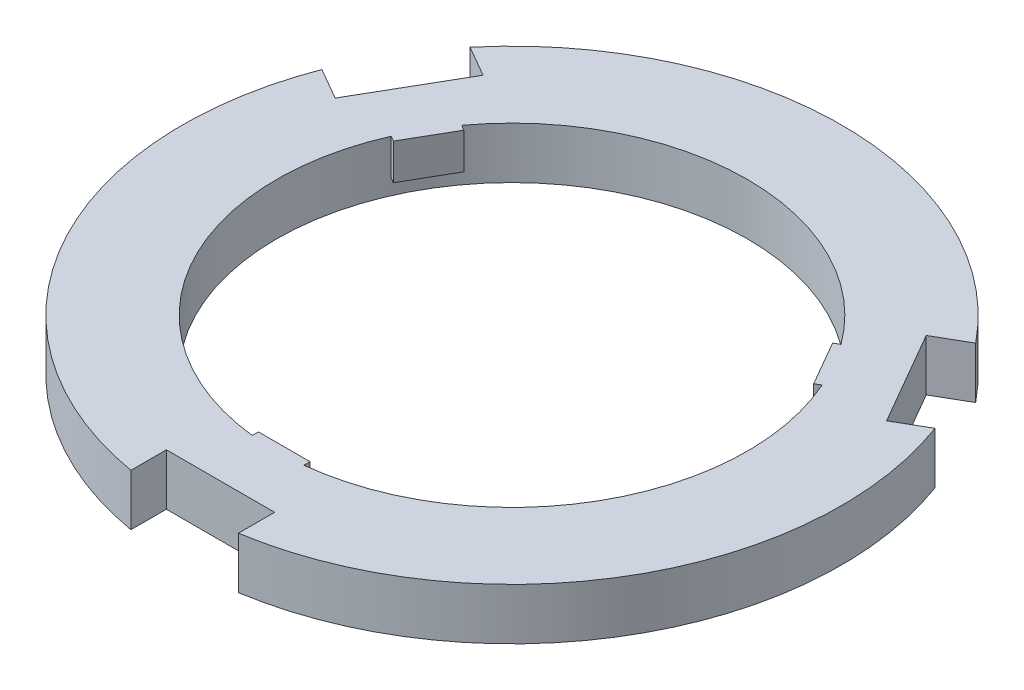
from build123d import *

# Parameters (mm, degrees)
BOSS_EXTRUDE4_DEPTH      = 3
BOSS_EXTRUDE5_START      = -2
BOSS_EXTRUDE5_DEPTH      = 2
BOSS_EXTRUDE6_DEPTH      = 3
BOSS_EXTRUDE6_DEPTH_BACK = 0.5


with BuildPart() as part:
    # Sketch2 → Boss-Extrude4 (new body)
    with BuildSketch(Plane(origin=(0, 0, 0), x_dir=(1, 0, 0), z_dir=(0, 1, 0))):
        with BuildLine():
            Line((-5.466491508, -31.529628456), (-5.466491508, -28.085827415))
            Line((-5.466491508, -28.085827415), (5.040547776, -28.085827415))
            Line((5.040547776, -28.085827415), (5.040547776, -31.600520219))
            ThreePointArc((5.040547776, -31.600520219), (27.604231444, -16.186611949), (30.038704969, 11.030693713))
            Line((30.038704969, 11.030693713), (27.056285781, 9.308793192))
            Line((27.056285781, 9.308793192), (21.802766139, 18.408156131))
            Line((21.802766139, 18.408156131), (24.846579394, 20.165502533))
            ThreePointArc((24.846579394, 20.165502533), (0.215901427, 31.999271657), (-24.572213461, 20.498934743))
            Line((-24.572213461, 20.498934743), (-21.589794274, 18.777034223))
            Line((-21.589794274, 18.777034223), (-26.843313916, 9.677671284))
            Line((-26.843313916, 9.677671284), (-29.887127171, 11.435017686))
            ThreePointArc((-29.887127171, 11.435017686), (-27.820132871, -15.812659708), (-5.466491508, -31.529628456))
        make_face()
        with BuildLine():
            ThreePointArc((2.502594182, -22.712052772), (0, -22.849514629), (-2.502594182, -22.712052772))
            ThreePointArc((-2.502594182, -22.712052772), (-19.788260133, -11.424757314), (-20.920511764, 9.188716249))
            ThreePointArc((-20.920511764, 9.188716249), (-19.788260133, 11.424757314), (-18.417917582, 13.523336524))
            ThreePointArc((-18.417917582, 13.523336524), (0, 22.849514629), (18.417917582, 13.523336524))
            ThreePointArc((18.417917582, 13.523336524), (19.788260133, 11.424757314), (20.920511764, 9.188716249))
            ThreePointArc((20.920511764, 9.188716249), (22.362064511, 4.69450632), (22.849514629, 0))
            ThreePointArc((22.849514629, 0), (17.018862787, -15.246593987), (2.502594182, -22.712052772))
        make_face(mode=Mode.SUBTRACT)
    extrude(amount=BOSS_EXTRUDE4_DEPTH)

    # Sketch2_12 → Boss-Extrude5 (add)
    with BuildSketch(Plane(origin=(0, 0, 0), x_dir=(1, 0, 0), z_dir=(0, 1, 0)).offset(BOSS_EXTRUDE5_START)):
        with BuildLine():
            Line((-5.466491508, -31.529628456), (-5.466491508, -28.085827415))
            Line((-5.466491508, -28.085827415), (5.040547776, -28.085827415))
            Line((5.040547776, -28.085827415), (5.040547776, -31.600520219))
            ThreePointArc((5.040547776, -31.600520219), (27.604231444, -16.186611949), (30.038704969, 11.030693713))
            Line((30.038704969, 11.030693713), (27.056285781, 9.308793192))
            Line((27.056285781, 9.308793192), (21.802766139, 18.408156131))
            Line((21.802766139, 18.408156131), (24.846579394, 20.165502533))
            ThreePointArc((24.846579394, 20.165502533), (0.215901427, 31.999271657), (-24.572213461, 20.498934743))
            Line((-24.572213461, 20.498934743), (-21.589794274, 18.777034223))
            Line((-21.589794274, 18.777034223), (-26.843313916, 9.677671284))
            Line((-26.843313916, 9.677671284), (-29.887127171, 11.435017686))
            ThreePointArc((-29.887127171, 11.435017686), (-27.820132871, -15.812659708), (-5.466491508, -31.529628456))
        make_face()
        with BuildLine():
            ThreePointArc((2.502594182, -22.712052772), (0, -22.849514629), (-2.502594182, -22.712052772))
            ThreePointArc((-2.502594182, -22.712052772), (-19.788260133, -11.424757314), (-20.920511764, 9.188716249))
            ThreePointArc((-20.920511764, 9.188716249), (-19.788260133, 11.424757314), (-18.417917582, 13.523336524))
            ThreePointArc((-18.417917582, 13.523336524), (0, 22.849514629), (18.417917582, 13.523336524))
            ThreePointArc((18.417917582, 13.523336524), (19.788260133, 11.424757314), (20.920511764, 9.188716249))
            ThreePointArc((20.920511764, 9.188716249), (22.362064511, 4.69450632), (22.849514629, 0))
            ThreePointArc((22.849514629, 0), (17.018862787, -15.246593987), (2.502594182, -22.712052772))
        make_face(mode=Mode.SUBTRACT)
    extrude(amount=BOSS_EXTRUDE5_DEPTH)

    # Sketch2_13 → Boss-Extrude6 (add, two sides: drawn at the far end of the back side and taken through both)
    with BuildSketch(Plane(origin=(0, 0, 0), x_dir=(1, 0, 0), z_dir=(0, 1, 0)).offset(-BOSS_EXTRUDE6_DEPTH_BACK)):
        with BuildLine():
            Line((2.502594182, -22.112052772), (-2.502594182, -22.112052772))
            Line((-2.502594182, -22.112052772), (-2.502594182, -22.712052772))
            ThreePointArc((-2.502594182, -22.712052772), (0, -22.849514629), (2.502594182, -22.712052772))
            Line((2.502594182, -22.712052772), (2.502594182, -22.112052772))
        make_face()
        with BuildLine():
            ThreePointArc((-18.417917582, 13.523336524), (-19.788260133, 11.424757314), (-20.920511764, 9.188716249))
            Line((-20.920511764, 9.188716249), (-20.400896522, 8.888716249))
            Line((-20.400896522, 8.888716249), (-17.89830234, 13.223336524))
            Line((-17.89830234, 13.223336524), (-18.417917582, 13.523336524))
        make_face()
        with BuildLine():
            Line((20.400896522, 8.888716249), (20.920511764, 9.188716249))
            ThreePointArc((20.920511764, 9.188716249), (19.788260133, 11.424757314), (18.417917582, 13.523336524))
            Line((18.417917582, 13.523336524), (17.89830234, 13.223336524))
            Line((17.89830234, 13.223336524), (20.400896522, 8.888716249))
        make_face()
    extrude(amount=BOSS_EXTRUDE6_DEPTH + BOSS_EXTRUDE6_DEPTH_BACK)


solid = part.part
